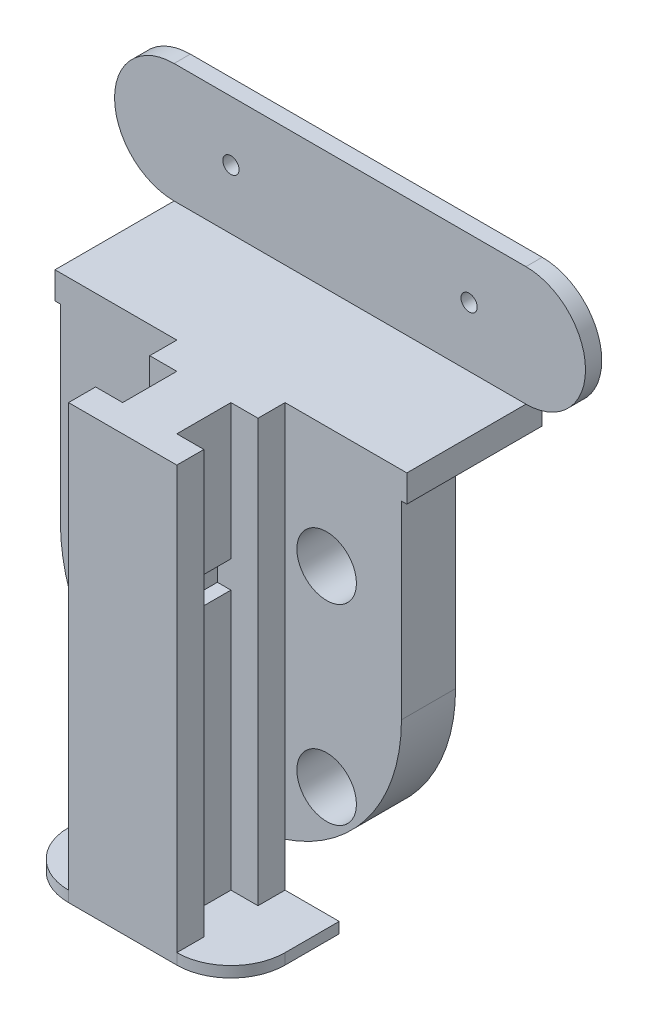
from build123d import *

# Parameters (mm, degrees)
SKETCH1_R                = 5.5
BOSS_EXTRUDE1_DEPTH      = 10
SKETCH1_3_R              = 5.5
SKETCH1_3_R_2            = 2.5
BOSS_EXTRUDE2_DEPTH      = 2
SKETCH1_4_R              = 2.5
BOSS_EXTRUDE3_DEPTH      = 5
BOSS_EXTRUDE4_DEPTH      = 5
SKETCH4_W                = 20
SKETCH4_H                = 80
BOSS_EXTRUDE5_DEPTH      = 20
SKETCH5_W                = 20
SKETCH5_H                = 2
BOSS_EXTRUDE6_DEPTH      = 10
BOSS_EXTRUDE6_DEPTH_BACK = 30
SKETCH7_W                = 5
SKETCH7_H                = 10
CUT_EXTRUDE1_DEPTH       = 78
FILLET1_R                = 10
SKETCH9_W                = 10
SKETCH9_H                = 5
CUT_EXTRUDE2_DEPTH       = 2.5
SKETCH14_R               = 1.5
BOSS_EXTRUDE8_DEPTH      = 3
SKETCH16_W               = 10
SKETCH16_H               = 5
CUT_EXTRUDE4_DEPTH       = 2.5


with BuildPart() as part:
    # Sketch1 → Boss-Extrude1 (new body)
    with BuildSketch(Plane.XY):
        with BuildLine():
            Line((31.5, 0), (31.5, 40))
            Line((31.5, 40), (-31.5, 40))
            Line((-31.5, 40), (-31.5, 0))
            ThreePointArc((-31.5, 0), (0, -31.5), (31.5, 0))
        make_face()
        with Locations((17.67766953, -17.67766953)):
            Circle(SKETCH1_R, mode=Mode.SUBTRACT)
        with Locations((-17.67766953, -17.67766953)):
            Circle(SKETCH1_R, mode=Mode.SUBTRACT)
        with Locations((-17.67766953, 17.67766953)):
            Circle(SKETCH1_R, mode=Mode.SUBTRACT)
        with Locations((17.67766953, 17.67766953)):
            Circle(SKETCH1_R, mode=Mode.SUBTRACT)
    extrude(amount=BOSS_EXTRUDE1_DEPTH)

    # Sketch1_3 → Boss-Extrude2 (add)
    with BuildSketch(Plane.XY):
        with Locations((17.67766953, 17.67766953)):
            Circle(SKETCH1_3_R)
        with Locations((17.67766953, 17.67766953)):
            Circle(SKETCH1_3_R_2, mode=Mode.SUBTRACT)
        with Locations((17.67766953, -17.67766953)):
            Circle(SKETCH1_3_R)
        with Locations((17.67766953, -17.67766953)):
            Circle(SKETCH1_3_R_2, mode=Mode.SUBTRACT)
        with Locations((-17.67766953, -17.67766953)):
            Circle(SKETCH1_3_R)
        with Locations((-17.67766953, -17.67766953)):
            Circle(SKETCH1_3_R_2, mode=Mode.SUBTRACT)
        with Locations((-17.67766953, 17.67766953)):
            Circle(SKETCH1_3_R)
        with Locations((-17.67766953, 17.67766953)):
            Circle(SKETCH1_3_R_2, mode=Mode.SUBTRACT)
    extrude(amount=BOSS_EXTRUDE2_DEPTH)

    # Sketch1_4 → Boss-Extrude3 (add)
    with BuildSketch(Plane.XY):
        with Locations((0, 25)):
            Circle(SKETCH1_4_R)
    extrude(amount=-BOSS_EXTRUDE3_DEPTH)

    # Sketch2 → Boss-Extrude4 (add)
    with BuildSketch(Plane(origin=(0, 40, 0), x_dir=(1, 0, 0), z_dir=(0, 1, 0))):
        Polygon((-32.5, -10), (31.5, -10), (32.5, -10), (32.5, 15), (-32.5, 15), align=None)
    extrude(amount=-BOSS_EXTRUDE4_DEPTH)

    # Sketch4 → Boss-Extrude5 (add)
    with BuildSketch(Plane.XY.offset(10)):
        Rectangle(SKETCH4_W, SKETCH4_H)
    extrude(amount=BOSS_EXTRUDE5_DEPTH)

    # Sketch5 → Boss-Extrude6 (add, two sides)
    with BuildSketch(Plane(origin=(10, 0, 0), x_dir=(0, 0, -1), z_dir=(1, 0, 0))) as boss_extrude6_sk:
        with Locations((-20, -39)):
            Rectangle(SKETCH5_W, SKETCH5_H)
    extrude(amount=BOSS_EXTRUDE6_DEPTH)
    extrude(boss_extrude6_sk.sketch, amount=-BOSS_EXTRUDE6_DEPTH_BACK)

    # Sketch7 → Cut-Extrude1 (cut)
    with BuildSketch(Plane(origin=(0, 40, 0), x_dir=(1, 0, 0), z_dir=(0, 1, 0))):
        with Locations((-7.5, -20)):
            Rectangle(SKETCH7_W, SKETCH7_H)
        with Locations((7.5, -20)):
            Rectangle(SKETCH7_W, SKETCH7_H)
    extrude(amount=-CUT_EXTRUDE1_DEPTH, mode=Mode.SUBTRACT)

    # Fillet1
    fillet1_edges = [part.edges().sort_by_distance(p)[0] for p in [
        (-20, -39, 30),
        (20, -39, 30),
    ]]
    fillet(fillet1_edges, radius=FILLET1_R)

    # Sketch9 → Cut-Extrude2 (cut)
    with BuildSketch(Plane(origin=(5, 0, 0), x_dir=(0, 0, -1), z_dir=(1, 0, 0))):
        with Locations((-20, 12.5)):
            Rectangle(SKETCH9_W, SKETCH9_H)
    extrude(amount=-CUT_EXTRUDE2_DEPTH, mode=Mode.SUBTRACT)

    # Sketch14 → Boss-Extrude8 (add)
    with BuildSketch(Plane(origin=(0, 0, -15), x_dir=(-1, 0, 0), z_dir=(0, 0, -1))):
        with BuildLine():
            Line((32.5, 62), (-32.5, 62))
            ThreePointArc((-32.5, 62), (-43.5, 51), (-32.5, 40))
            Line((-32.5, 40), (32.5, 40))
            ThreePointArc((32.5, 40), (43.5, 51), (32.5, 62))
        make_face()
        with Locations((-22, 51)):
            Circle(SKETCH14_R, mode=Mode.SUBTRACT)
        with Locations((22, 51)):
            Circle(SKETCH14_R, mode=Mode.SUBTRACT)
    extrude(amount=-BOSS_EXTRUDE8_DEPTH)

    # Sketch16 → Cut-Extrude4 (cut)
    with BuildSketch(Plane.ZY.offset(5)):
        with Locations((20, 12.5)):
            Rectangle(SKETCH16_W, SKETCH16_H)
    extrude(amount=-CUT_EXTRUDE4_DEPTH, mode=Mode.SUBTRACT)


solid = part.part
